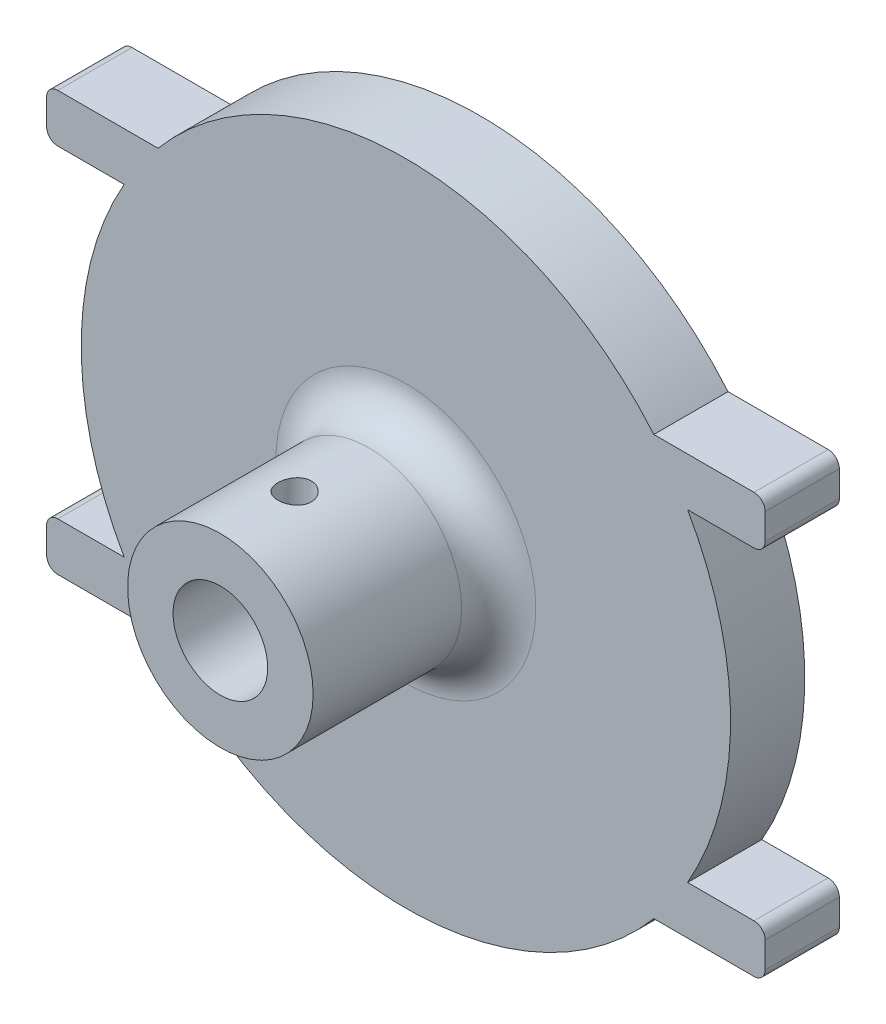
from build123d import *

# Parameters (mm, degrees)
BOSS_EXTRUDE1_DEPTH = 5.08
SKETCH5_R           = 9.6901
CUT_EXTRUDE2_DEPTH  = 2.54
SKETCH6_R           = 6.35
SKETCH6_R_2         = 3.2385
BOSS_EXTRUDE4_DEPTH = 12.7
FILLET1_R           = 2.54
SKETCH8_R           = 1.143
CUT_EXTRUDE3_DEPTH  = 7.62


with BuildPart() as part:
    # Sketch1 → Boss-Extrude1 (new body)
    with BuildSketch(Plane.XY):
        with BuildLine():
            Line((-23.828545778, 14.351), (-16.970545778, 14.351))
            ThreePointArc((-16.970545778, 14.351), (0, 22.225), (16.970545778, 14.351))
            Line((16.970545778, 14.351), (23.828545778, 14.351))
            ThreePointArc((23.828545778, 14.351), (24.367361145, 14.127815367), (24.590545778, 13.589))
            Line((24.590545778, 13.589), (24.590545778, 11.811))
            ThreePointArc((24.590545778, 11.811), (24.367361145, 11.272184633), (23.828545778, 11.049))
            Line((23.828545778, 11.049), (19.283936942, 11.049))
            ThreePointArc((19.283936942, 11.049), (22.225, 0), (19.283936942, -11.049))
            Line((19.283936942, -11.049), (23.828545778, -11.049))
            ThreePointArc((23.828545778, -11.049), (24.367361145, -11.272184633), (24.590545778, -11.811))
            Line((24.590545778, -11.811), (24.590545778, -13.589))
            ThreePointArc((24.590545778, -13.589), (24.367361145, -14.127815367), (23.828545778, -14.351))
            Line((23.828545778, -14.351), (16.970545778, -14.351))
            ThreePointArc((16.970545778, -14.351), (0, -22.225), (-16.970545778, -14.351))
            Line((-16.970545778, -14.351), (-23.828545778, -14.351))
            ThreePointArc((-23.828545778, -14.351), (-24.367361145, -14.127815367), (-24.590545778, -13.589))
            Line((-24.590545778, -13.589), (-24.590545778, -11.811))
            ThreePointArc((-24.590545778, -11.811), (-24.367361145, -11.272184633), (-23.828545778, -11.049))
            Line((-23.828545778, -11.049), (-19.283936942, -11.049))
            ThreePointArc((-19.283936942, -11.049), (-22.225, 0), (-19.283936942, 11.049))
            Line((-19.283936942, 11.049), (-23.828545778, 11.049))
            ThreePointArc((-23.828545778, 11.049), (-24.367361145, 11.272184633), (-24.590545778, 11.811))
            Line((-24.590545778, 11.811), (-24.590545778, 13.589))
            ThreePointArc((-24.590545778, 13.589), (-24.367361145, 14.127815367), (-23.828545778, 14.351))
        make_face()
    extrude(amount=BOSS_EXTRUDE1_DEPTH)

    # Sketch5 → Cut-Extrude2 (cut)
    with BuildSketch(Plane(origin=(0, 0, 0), x_dir=(-1, 0, 0), z_dir=(0, 0, -1))):
        Circle(SKETCH5_R)
    extrude(amount=-CUT_EXTRUDE2_DEPTH, mode=Mode.SUBTRACT)

    # Sketch6 → Boss-Extrude4 (add)
    with BuildSketch(Plane.XY.offset(5.08)):
        Circle(SKETCH6_R)
        Circle(SKETCH6_R_2, mode=Mode.SUBTRACT)
    extrude(amount=BOSS_EXTRUDE4_DEPTH)

    # Fillet1
    fillet1_edges = [part.edges().sort_by_distance(p)[0] for p in [
        (-6.35, 0, 5.08),
    ]]
    fillet(fillet1_edges, radius=FILLET1_R)

    # Sketch8 → Cut-Extrude3 (cut)
    with BuildSketch(Plane(origin=(0, 6.35, 0), x_dir=(1, 0, 0), z_dir=(0, 1, 0))):
        with Locations((0, -12.7)):
            Circle(SKETCH8_R)
    extrude(amount=-CUT_EXTRUDE3_DEPTH, mode=Mode.SUBTRACT)


solid = part.part
